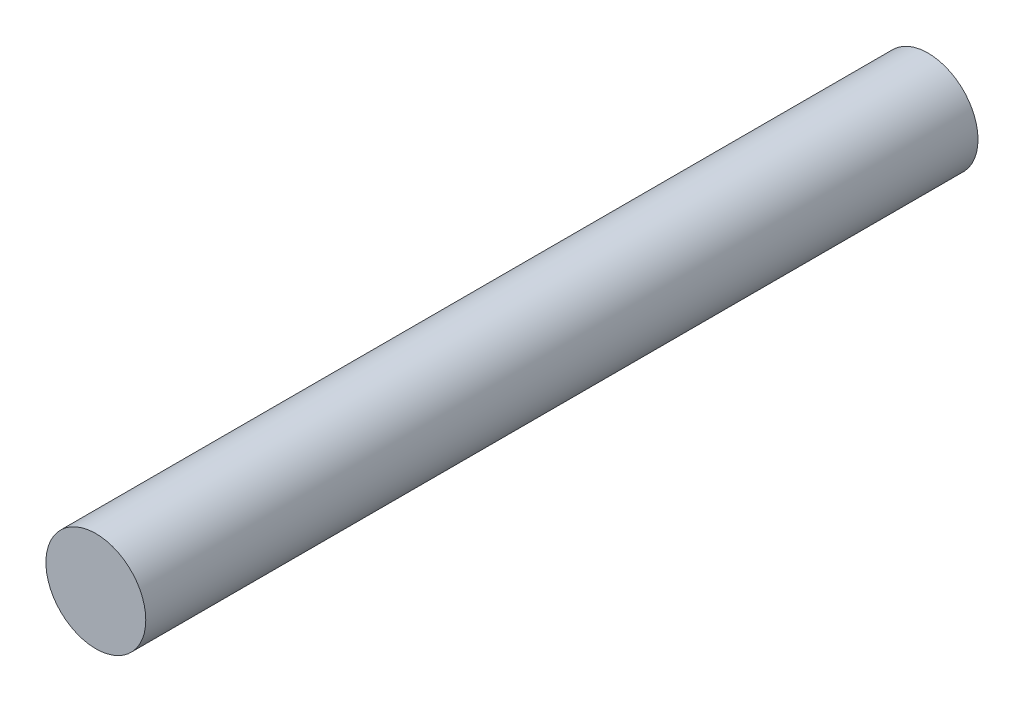
from build123d import *

# Parameters (mm, degrees)
CROQUIS1_R              = 3
SALIENTE_EXTRUIR1_DEPTH = 50


with BuildPart() as part:
    # Croquis1 → Saliente-Extruir1 (new body)
    with BuildSketch(Plane.XY):
        Circle(CROQUIS1_R)
    extrude(amount=SALIENTE_EXTRUIR1_DEPTH)


solid = part.part
